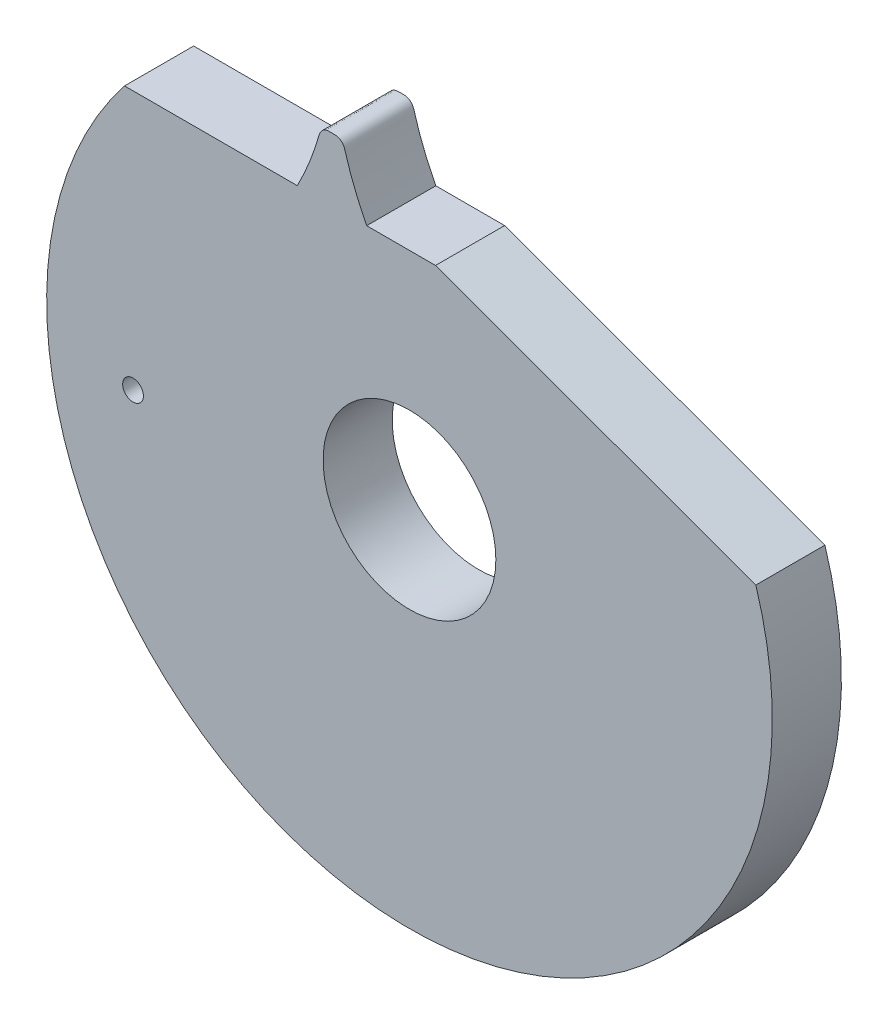
from build123d import *

# Parameters (mm, degrees)
CROQUIS1_R              = 0.625
CROQUIS1_R_2            = 0.075
SALIENTE_EXTRUIR1_DEPTH = 0.5


with BuildPart() as part:
    # Croquis1 → Saliente-Extruir1 (new body)
    with BuildSketch(Plane.XY):
        with BuildLine():
            Line((-2.061552813, 1.625), (-0.811552813, 1.625))
            add(Edge.make_bspline(
                [(-0.811552813, 1.625), (-0.798782356, 1.649959349), (-0.782498238, 1.683090879), (-0.763347126, 1.72442316), (-0.752712149, 1.748064852), (-0.74262377, 1.771178381), (-0.733068825, 1.793754559), (-0.724034006, 1.815784432), (-0.715505878, 1.837259275), (-0.707470863, 1.858170593), (-0.699915302, 1.878510138), (-0.692825255, 1.898269854), (-0.686187231, 1.917442077), (-0.679985615, 1.936018832), (-0.674211779, 1.953994338), (-0.668831938, 1.971356162), (-0.66341026, 1.989782298), (-0.659291042, 2.003761573), (-0.65673809, 2.013593254), (-0.65553735, 2.017655932), (-0.654243192, 2.021674167), (-0.652826724, 2.025662873), (-0.651269039, 2.029644141), (-0.649539563, 2.033642415), (-0.647598658, 2.037685942), (-0.645392531, 2.041805901), (-0.642848792, 2.046034827), (-0.639870281, 2.050402579), (-0.636328384, 2.054928152), (-0.6320578, 2.059604348), (-0.626858125, 2.064372328), (-0.620512998, 2.06908401), (-0.612841423, 2.073466371), (-0.60379299, 2.077092613), (-0.593874768, 2.079431243), (-0.579295505, 2.080347541), (-0.560560129, 2.079632007), (-0.541824754, 2.080347541), (-0.52724549, 2.079431243), (-0.517327269, 2.077092613), (-0.508278836, 2.073466371), (-0.500607261, 2.06908401), (-0.494262134, 2.064372328), (-0.489062459, 2.059604348), (-0.484791875, 2.054928152), (-0.481249978, 2.050402579), (-0.478271466, 2.046034827), (-0.475727728, 2.041805901), (-0.473521601, 2.037685942), (-0.471580696, 2.033642415), (-0.46985122, 2.029644141), (-0.468293535, 2.025662873), (-0.466877067, 2.021674167), (-0.465582909, 2.017655932), (-0.464382169, 2.013593254), (-0.461829216, 2.003761573), (-0.457709999, 1.989782298), (-0.452288321, 1.971356162), (-0.44690848, 1.953994338), (-0.441134644, 1.936018832), (-0.434933028, 1.917442077), (-0.428295003, 1.898269854), (-0.421204957, 1.878510138), (-0.413649396, 1.858170593), (-0.405614381, 1.837259275), (-0.397086252, 1.815784432), (-0.388051434, 1.793754559), (-0.378496489, 1.771178381), (-0.36840811, 1.748064852), (-0.357773133, 1.72442316), (-0.338622021, 1.683090879), (-0.322337903, 1.649959349), (-0.309567446, 1.625)],
                knots=[0, 0, 0, 0, 0.076643471, 0.100907917, 0.124530541, 0.147511341, 0.169850319, 0.191547473, 0.212602804, 0.233016312, 0.252787997, 0.271917859, 0.290405898, 0.308252114, 0.325456506, 0.342019076, 0.357939822, 0.377966124, 0.381853223, 0.38570675, 0.389545591, 0.393392716, 0.39727624, 0.401230769, 0.405299107, 0.409534341, 0.414002283, 0.418784036, 0.423978014, 0.429699889, 0.436077405, 0.443234951, 0.45126173, 0.460161641, 0.469798585, 0.478975881, 0.5, 0.521024119, 0.530201415, 0.539838359, 0.54873827, 0.556765049, 0.563922595, 0.570300111, 0.576021986, 0.581215964, 0.585997717, 0.590465659, 0.594700893, 0.598769231, 0.60272376, 0.606607284, 0.610454409, 0.61429325, 0.618146777, 0.622033876, 0.642060178, 0.657980924, 0.674543494, 0.691747886, 0.709594102, 0.728082141, 0.747212003, 0.766983688, 0.787397196, 0.808452527, 0.830149681, 0.852488659, 0.875469459, 0.899092083, 0.923356529, 1, 1, 1, 1], degree=3))
            Line((-0.309567446, 1.625), (0.188447187, 1.625))
            Line((0.188447187, 1.625), (2.505972628, 0.781489722))
            ThreePointArc((2.505972628, 0.781489722), (-0.476712324, -2.581350491), (-2.061552813, 1.625))
        make_face()
        Circle(CROQUIS1_R, mode=Mode.SUBTRACT)
        with Locations((-2, -0.25)):
            Circle(CROQUIS1_R_2, mode=Mode.SUBTRACT)
    extrude(amount=SALIENTE_EXTRUIR1_DEPTH)


solid = part.part
